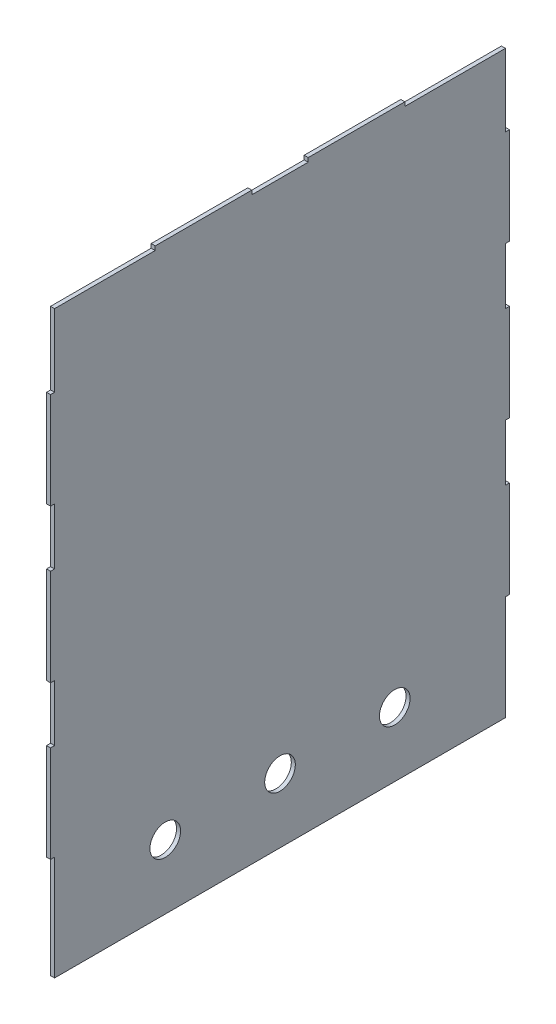
from build123d import *

# Parameters (mm, degrees)
SKETCH1_W           = 361.95
SKETCH1_H           = 460.375
BOSS_EXTRUDE1_DEPTH = 3.175
SKETCH2_W           = 3.175
SKETCH2_H           = 82.55
SKETCH2_H_2         = 44.45
SKETCH2_W_2         = 22.225
SKETCH2_H_3         = 3.175
CUT_EXTRUDE1_DEPTH  = 3.175
SKETCH3_R           = 12.0777
CUT_EXTRUDE2_DEPTH  = 3.175


with BuildPart() as part:
    # Sketch1 → Boss-Extrude1 (new body)
    with BuildSketch(Plane(origin=(0, 0, 0), x_dir=(0, 0, -1), z_dir=(1, 0, 0))):
        with Locations((0, 230.1875)):
            Rectangle(SKETCH1_W, SKETCH1_H)
    extrude(amount=BOSS_EXTRUDE1_DEPTH)

    # Sketch2 → Cut-Extrude1 (cut)
    with BuildSketch(Plane(origin=(3.175, 0, 0), x_dir=(0, 0, -1), z_dir=(1, 0, 0))):
        with Locations((-179.3875, 41.275)):
            Rectangle(SKETCH2_W, SKETCH2_H)
        with Locations((-179.3875, 180.975)):
            Rectangle(SKETCH2_W, SKETCH2_H_2)
        with Locations((-179.3875, 301.625)):
            Rectangle(SKETCH2_W, SKETCH2_H_2)
        Polygon((-98.425, 460.375), (-180.975, 460.375), (-180.975, 400.05), (-177.8, 400.05), (-177.8, 457.2), (-98.425, 457.2), align=None)
        with Locations((-11.1125, 458.7875)):
            Rectangle(SKETCH2_W_2, SKETCH2_H_3)
        with Locations((11.1125, 458.7875)):
            Rectangle(SKETCH2_W_2, SKETCH2_H_3)
        Polygon((180.975, 460.375), (98.425, 460.375), (98.425, 457.2), (177.8, 457.2), (177.8, 400.05), (180.975, 400.05), align=None)
        with Locations((179.3875, 301.625)):
            Rectangle(SKETCH2_W, SKETCH2_H_2)
        with Locations((179.3875, 180.975)):
            Rectangle(SKETCH2_W, SKETCH2_H_2)
        with Locations((179.3875, 41.275)):
            Rectangle(SKETCH2_W, SKETCH2_H)
    extrude(amount=-CUT_EXTRUDE1_DEPTH, mode=Mode.SUBTRACT)

    # Sketch3 → Cut-Extrude2 (cut)
    with BuildSketch(Plane(origin=(3.175, 0, 0), x_dir=(0, 0, -1), z_dir=(1, 0, 0))):
        with Locations((0, 50.8)):
            Circle(SKETCH3_R)
        with Locations((-90.5002, 50.8)):
            Circle(SKETCH3_R)
        with Locations((90.5002, 50.8)):
            Circle(SKETCH3_R)
    extrude(amount=-CUT_EXTRUDE2_DEPTH, mode=Mode.SUBTRACT)


solid = part.part
